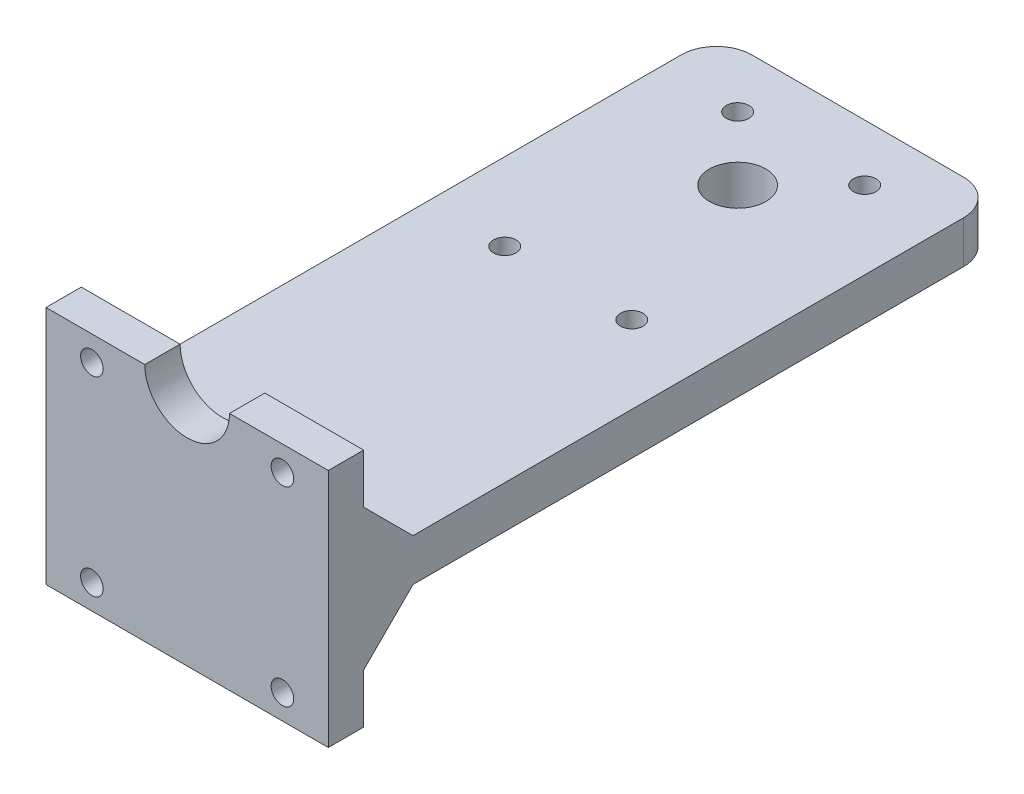
from build123d import *

# Parameters (mm, degrees)
SKETCH_1_W          = 40
SKETCH_1_H          = 95
SKETCH_1_R          = 4
SKETCH_1_R_2        = 1.6
EXTRUDE_1_DEPTH     = 6
SKETCH_2_W          = 40
SKETCH_2_H          = 5
EXTRUDE_2_DEPTH     = 14
SKETCH_3_R          = 6
CUT_EXTRUDE_1_DEPTH = 14
CHAMFER_1_SIZE      = 7
SKETCH_4_R          = 1.6
CUT_EXTRUDE_2_DEPTH = 14
FILLET_1_R          = 5
EXTRUDE_3_DEPTH     = 40
SKETCH_7_R          = 1.6
CUT_EXTRUDE_3_DEPTH = 40


with BuildPart() as part:
    # Эскиз1 → Бобышка-Вытянуть1 (new body)
    with BuildSketch(Plane(origin=(0, 0, 0), x_dir=(1, 0, 0), z_dir=(0, 1, 0))):
        with Locations((0, 47.5)):
            Rectangle(SKETCH_1_W, SKETCH_1_H)
        with Locations((0, 78)):
            Circle(SKETCH_1_R, mode=Mode.SUBTRACT)
        with Locations((-9, 87)):
            Circle(SKETCH_1_R_2, mode=Mode.SUBTRACT)
        with Locations((9, 87)):
            Circle(SKETCH_1_R_2, mode=Mode.SUBTRACT)
        with Locations((-9, 54)):
            Circle(SKETCH_1_R_2, mode=Mode.SUBTRACT)
        with Locations((9, 54)):
            Circle(SKETCH_1_R_2, mode=Mode.SUBTRACT)
    extrude(amount=EXTRUDE_1_DEPTH)

    # Эскиз2 → Бобышка-Вытянуть2 (add)
    with BuildSketch(Plane(origin=(0, 6, 0), x_dir=(1, 0, 0), z_dir=(0, 1, 0))):
        with Locations((0, 2.5)):
            Rectangle(SKETCH_2_W, SKETCH_2_H)
    extrude(amount=EXTRUDE_2_DEPTH)

    # Эскиз3 → Вырез-Вытянуть1 (cut)
    with BuildSketch(Plane(origin=(0, 0, -5), x_dir=(-1, 0, 0), z_dir=(0, 0, -1))):
        with Locations((0, 20)):
            Circle(SKETCH_3_R)
    extrude(amount=-CUT_EXTRUDE_1_DEPTH, mode=Mode.SUBTRACT)

    # Фаска1
    chamfer_1_edges = [part.edges().sort_by_distance(p)[0] for p in [
        (0, 6, -5),
    ]]
    chamfer(chamfer_1_edges, length=CHAMFER_1_SIZE)

    # Эскиз4 → Вырез-Вытянуть2 (cut)
    with BuildSketch(Plane(origin=(0, 0, -5), x_dir=(-1, 0, 0), z_dir=(0, 0, -1))):
        with Locations((13.5, 16.5)):
            Circle(SKETCH_4_R)
        with Locations((-13.5, 16.5)):
            Circle(SKETCH_4_R)
    extrude(amount=-CUT_EXTRUDE_2_DEPTH, mode=Mode.SUBTRACT)

    # Скругление1
    fillet_1_edges = [part.edges().sort_by_distance(p)[0] for p in [
        (-20, 3, -95),
        (20, 3, -95),
    ]]
    fillet(fillet_1_edges, radius=FILLET_1_R)

    # Эскиз5 → Бобышка-Вытянуть3 (add)
    with BuildSketch(Plane(origin=(20, 0, 0), x_dir=(0, 0, -1), z_dir=(1, 0, 0))):
        Polygon((5, -7), (5, -14), (0, -14), (0, 0), (12, 0), align=None)
    extrude(amount=-EXTRUDE_3_DEPTH)

    # Эскиз7 → Вырез-Вытянуть3 (cut)
    with BuildSketch(Plane.XY):
        with Locations((13.5, -10.5)):
            Circle(SKETCH_7_R)
        with Locations((-13.5, -10.5)):
            Circle(SKETCH_7_R)
    extrude(amount=-CUT_EXTRUDE_3_DEPTH, mode=Mode.SUBTRACT)


solid = part.part
